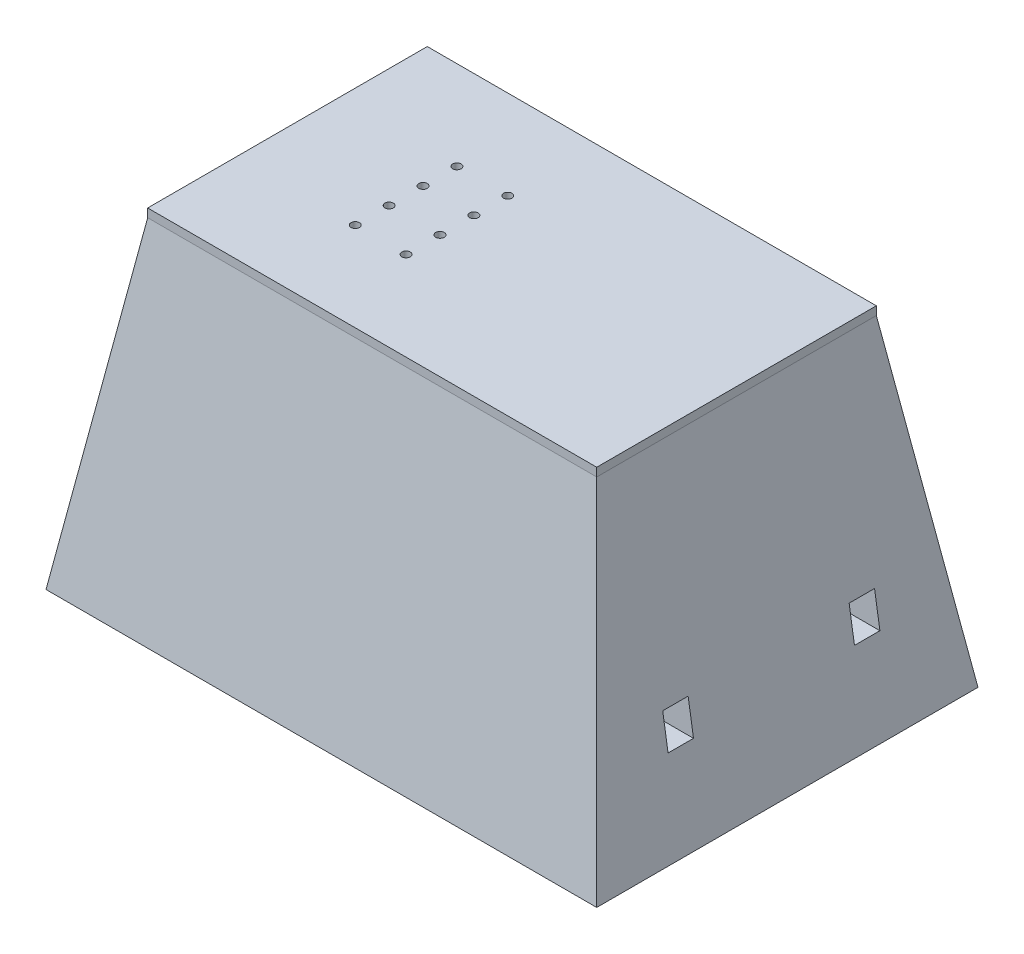
from build123d import *

# Parameters (mm, degrees)
SKETCH2_W           = 325
SKETCH2_H           = 225
SKETCH4_W           = 265
SKETCH4_H           = 165
SKETCH8_W           = 255
SKETCH8_H           = 155
SKETCH9_W           = 255
SKETCH9_H           = 155
SKETCH10_W          = 265
SKETCH10_H          = 165
BOSS_EXTRUDE1_DEPTH = 5
SKETCH13_W          = 10
SKETCH13_H          = 10
BOSS_EXTRUDE2_DEPTH = 162
SKETCH14_R          = 2.5
CUT_EXTRUDE1_DEPTH  = 196.0000001
CUT_EXTRUDE2_REACH  = 327
SKETCH15_W          = 15
SKETCH15_H          = 20


with BuildPart() as part:
    # Sketch2 → Loft2 section 0
    with BuildSketch(Plane(origin=(0, 0, 0), x_dir=(1, 0, 0), z_dir=(0, 1, 0))):
        with Locations((127.5, 77.5)):
            Rectangle(SKETCH2_W, SKETCH2_H)
    # Sketch4 → Loft2 section 1
    with BuildSketch(Plane(origin=(0, 190, 0), x_dir=(1, 0, 0), z_dir=(0, 1, 0))):
        with Locations((127.5, 77.5)):
            Rectangle(SKETCH4_W, SKETCH4_H)
    loft()

    # Sketch8 → Cut-Loft1 section 0
    with BuildSketch(Plane(origin=(0, 190, 0), x_dir=(1, 0, 0), z_dir=(0, 1, 0))):
        with Locations((127.5, 77.5)):
            Rectangle(SKETCH8_W, SKETCH8_H)
    # Sketch9 → Cut-Loft1 section 1
    with BuildSketch(Plane.XZ):
        with Locations((127.5, -77.5)):
            Rectangle(SKETCH9_W, SKETCH9_H)
    loft(mode=Mode.SUBTRACT)

    # Sketch10 → Boss-Extrude1 (add)
    with BuildSketch(Plane(origin=(0, 190, 0), x_dir=(1, 0, 0), z_dir=(0, 1, 0))):
        with Locations((127.5, 77.5)):
            Rectangle(SKETCH10_W, SKETCH10_H)
    extrude(amount=BOSS_EXTRUDE1_DEPTH)

    # Sketch13 → Boss-Extrude2 (add)
    with BuildSketch(Plane(origin=(0, 33, 0), x_dir=(1, 0, 0), z_dir=(0, 1, 0))):
        with Locations((5, 150)):
            Rectangle(SKETCH13_W, SKETCH13_H)
        with Locations((250, 150)):
            Rectangle(SKETCH13_W, SKETCH13_H)
        with Locations((250, 5)):
            Rectangle(SKETCH13_W, SKETCH13_H)
        with Locations((5, 5)):
            Rectangle(SKETCH13_W, SKETCH13_H)
    extrude(amount=BOSS_EXTRUDE2_DEPTH)

    # Sketch14 → Cut-Extrude1 (cut, through all)
    with BuildSketch(Plane(origin=(0, 195, 0), x_dir=(1, 0, 0), z_dir=(0, 1, 0))):
        with Locations((65, 47.5)):
            Circle(SKETCH14_R)
        with Locations((65, 67.5)):
            Circle(SKETCH14_R)
        with Locations((95, 67.5)):
            Circle(SKETCH14_R)
        with Locations((95, 47.5)):
            Circle(SKETCH14_R)
        with Locations((95, 107.5)):
            Circle(SKETCH14_R)
        with Locations((95, 87.5)):
            Circle(SKETCH14_R)
        with Locations((65, 87.5)):
            Circle(SKETCH14_R)
        with Locations((65, 107.5)):
            Circle(SKETCH14_R)
    extrude(amount=-CUT_EXTRUDE1_DEPTH, mode=Mode.SUBTRACT)

    # Sketch15 → Cut-Extrude2 (cut, up to next)
    with BuildSketch(Plane(origin=(290, 0, 0), x_dir=(0, 0, -1), z_dir=(1, 0, 0)), mode=Mode.PRIVATE) as cut_extrude2_sk1:
        with Locations((22.5, 60)):
            Rectangle(SKETCH15_W, SKETCH15_H)
    cut_extrude2_tool1 = extrude(cut_extrude2_sk1.sketch, amount=-CUT_EXTRUDE2_REACH, mode=Mode.PRIVATE) & part.part
    add(cut_extrude2_tool1.solids().sort_by_distance((290, 60, -22.5))[0], mode=Mode.SUBTRACT)
    # Sketch15 → Cut-Extrude2 (cut, up to next)
    with BuildSketch(Plane(origin=(290, 0, 0), x_dir=(0, 0, -1), z_dir=(1, 0, 0)), mode=Mode.PRIVATE) as cut_extrude2_sk2:
        with Locations((132.5, 60)):
            Rectangle(SKETCH15_W, SKETCH15_H)
    cut_extrude2_tool2 = extrude(cut_extrude2_sk2.sketch, amount=-CUT_EXTRUDE2_REACH, mode=Mode.PRIVATE) & part.part
    add(cut_extrude2_tool2.solids().sort_by_distance((290, 60, -132.5))[0], mode=Mode.SUBTRACT)


solid = part.part
